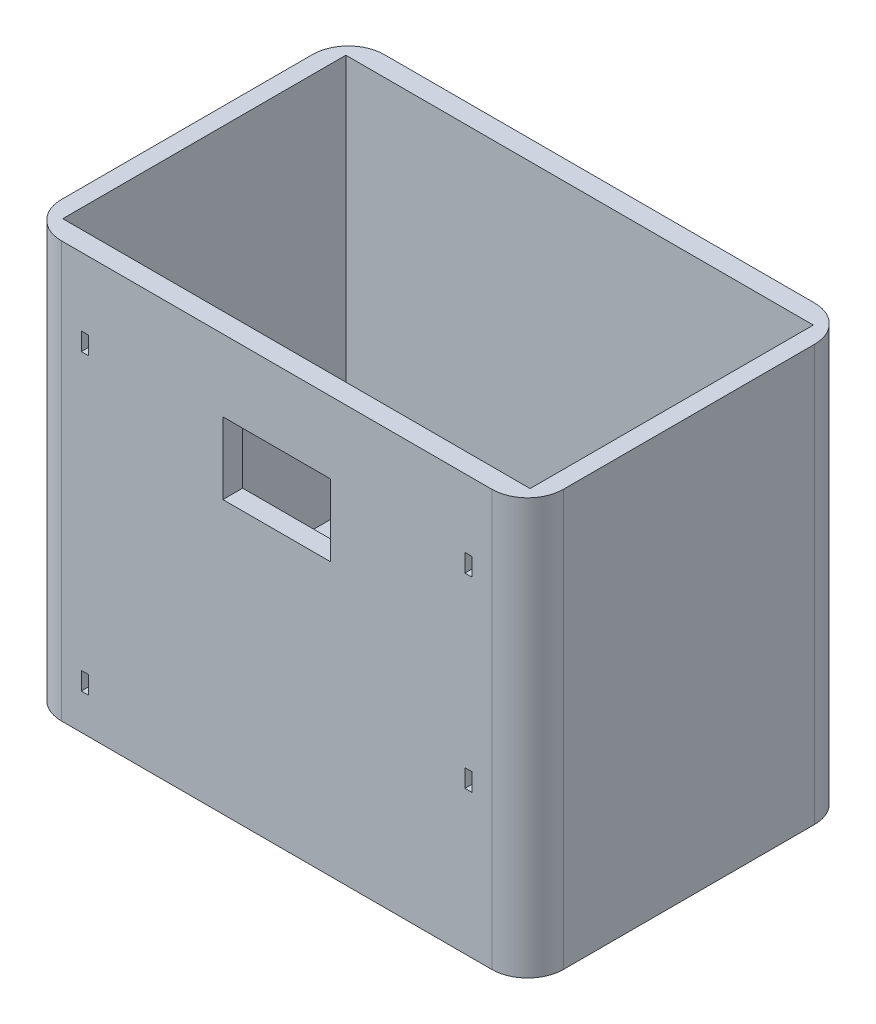
from build123d import *

# Parameters (mm, degrees)
SKETCH_1_W          = 70
SKETCH_1_H          = 45
EXTRUDE_1_DEPTH     = 3
SKETCH_2_W          = 13
SKETCH_2_H          = 23
CUT_EXTRUDE_1_DEPTH = 10
SKETCH_3_R          = 0.95
CUT_EXTRUDE_2_DEPTH = 10
FILLET_1_R          = 5
FILLET_2_R          = 5
SKETCH_4_R          = 0.95
CUT_EXTRUDE_3_DEPTH = 10
CUT_EXTRUDE_4_DEPTH = 10
SKETCH_9_W          = 65.182596022
SKETCH_9_H          = 39.488918008
EXTRUDE_2_DEPTH     = 55
SKETCH_10_W         = 1
SKETCH_10_H         = 2.5
SKETCH_10_W_2       = 15
SKETCH_10_H_2       = 10
CUT_EXTRUDE_5_DEPTH = 7


with BuildPart() as part:
    # 草图1 → 凸台-拉伸1 (new body)
    with BuildSketch(Plane(origin=(0, 0, 0), x_dir=(1, 0, 0), z_dir=(0, 1, 0))):
        Rectangle(SKETCH_1_W, SKETCH_1_H)
    extrude(amount=EXTRUDE_1_DEPTH)

    # 草图2 → 切除-拉伸1 (cut)
    with BuildSketch(Plane(origin=(0, 3, 0), x_dir=(1, 0, 0), z_dir=(0, 1, 0))):
        with Locations((24, 0)):
            Rectangle(SKETCH_2_W, SKETCH_2_H)
        with Locations((-24, 0)):
            Rectangle(SKETCH_2_W, SKETCH_2_H)
    extrude(amount=-CUT_EXTRUDE_1_DEPTH, mode=Mode.SUBTRACT)

    # 草图3 → 切除-拉伸2 (cut)
    with BuildSketch(Plane(origin=(0, 3, 0), x_dir=(1, 0, 0), z_dir=(0, 1, 0))):
        with Locations((-24, 14)):
            Circle(SKETCH_3_R)
        with Locations((-24, -14)):
            Circle(SKETCH_3_R)
        with Locations((24, 14)):
            Circle(SKETCH_3_R)
        with Locations((24, -14)):
            Circle(SKETCH_3_R)
    extrude(amount=-CUT_EXTRUDE_2_DEPTH, mode=Mode.SUBTRACT)

    # 圆角1
    fillet_1_edges = [part.edges().sort_by_distance(p)[0] for p in [
        (35, 1.5, -22.5),
    ]]
    fillet(fillet_1_edges, radius=FILLET_1_R)

    # 圆角2
    fillet_2_edges = [part.edges().sort_by_distance(p)[0] for p in [
        (35, 1.5, 22.5),
        (-35, 1.5, 22.5),
        (-35, 1.5, -22.5),
    ]]
    fillet(fillet_2_edges, radius=FILLET_2_R)

    # 草图4 → 切除-拉伸3 (cut)
    with BuildSketch(Plane(origin=(0, 3, 0), x_dir=(1, 0, 0), z_dir=(0, 1, 0))):
        with Locations((-30, 17.5)):
            Circle(SKETCH_4_R)
        with Locations((30, 17.5)):
            Circle(SKETCH_4_R)
        with Locations((-30, -17.5)):
            Circle(SKETCH_4_R)
        with Locations((30, -17.5)):
            Circle(SKETCH_4_R)
    extrude(amount=-CUT_EXTRUDE_3_DEPTH, mode=Mode.SUBTRACT)

    # 草图8 → 切除-拉伸4 (cut)
    with BuildSketch(Plane(origin=(0, 3, 0), x_dir=(1, 0, 0), z_dir=(0, 1, 0))):
        with BuildLine():
            Line((-27, 17.5), (27, 17.5))
            ThreePointArc((27, 17.5), (27.878679656, 15.378679656), (30, 14.5))
            Line((30, 14.5), (30, -14.5))
            ThreePointArc((30, -14.5), (27.878679656, -15.378679656), (27, -17.5))
            Line((27, -17.5), (-27, -17.5))
            ThreePointArc((-27, -17.5), (-27.878679656, -15.378679656), (-30, -14.5))
            Line((-30, -14.5), (-30, 14.5))
            ThreePointArc((-30, 14.5), (-27.878679656, 15.378679656), (-27, 17.5))
        make_face()
    extrude(amount=-CUT_EXTRUDE_4_DEPTH, mode=Mode.SUBTRACT)

    # 草图9 → 凸台-拉伸2 (add)
    with BuildSketch(Plane(origin=(0, 3, 0), x_dir=(1, 0, 0), z_dir=(0, 1, 0))):
        with BuildLine():
            Line((-30, -22.5), (30, -22.5))
            ThreePointArc((30, -22.5), (33.535533906, -21.035533906), (35, -17.5))
            Line((35, -17.5), (35, 17.5))
            ThreePointArc((35, 17.5), (33.535533906, 21.035533906), (30, 22.5))
            Line((30, 22.5), (-30, 22.5))
            ThreePointArc((-30, 22.5), (-33.535533906, 21.035533906), (-35, 17.5))
            Line((-35, 17.5), (-35, -17.5))
            ThreePointArc((-35, -17.5), (-33.535533906, -21.035533906), (-30, -22.5))
        make_face()
        Rectangle(SKETCH_9_W, SKETCH_9_H, mode=Mode.SUBTRACT)
    extrude(amount=EXTRUDE_2_DEPTH)

    # 草图10 → 切除-拉伸5 (cut)
    with BuildSketch(Plane(origin=(0, 0, 22.5), x_dir=(-1, 0, 0), z_dir=(0, 0, -1))):
        with Locations((26.75, 6.25)):
            Rectangle(SKETCH_10_W, SKETCH_10_H)
        with Locations((26.75, 47.25)):
            Rectangle(SKETCH_10_W, SKETCH_10_H)
        with Locations((-26.75, 21.25)):
            Rectangle(SKETCH_10_W, SKETCH_10_H)
        with Locations((-26.75, 47.25)):
            Rectangle(SKETCH_10_W, SKETCH_10_H)
        with Locations((0, 43)):
            Rectangle(SKETCH_10_W_2, SKETCH_10_H_2)
    extrude(amount=CUT_EXTRUDE_5_DEPTH, mode=Mode.SUBTRACT)


solid = part.part
